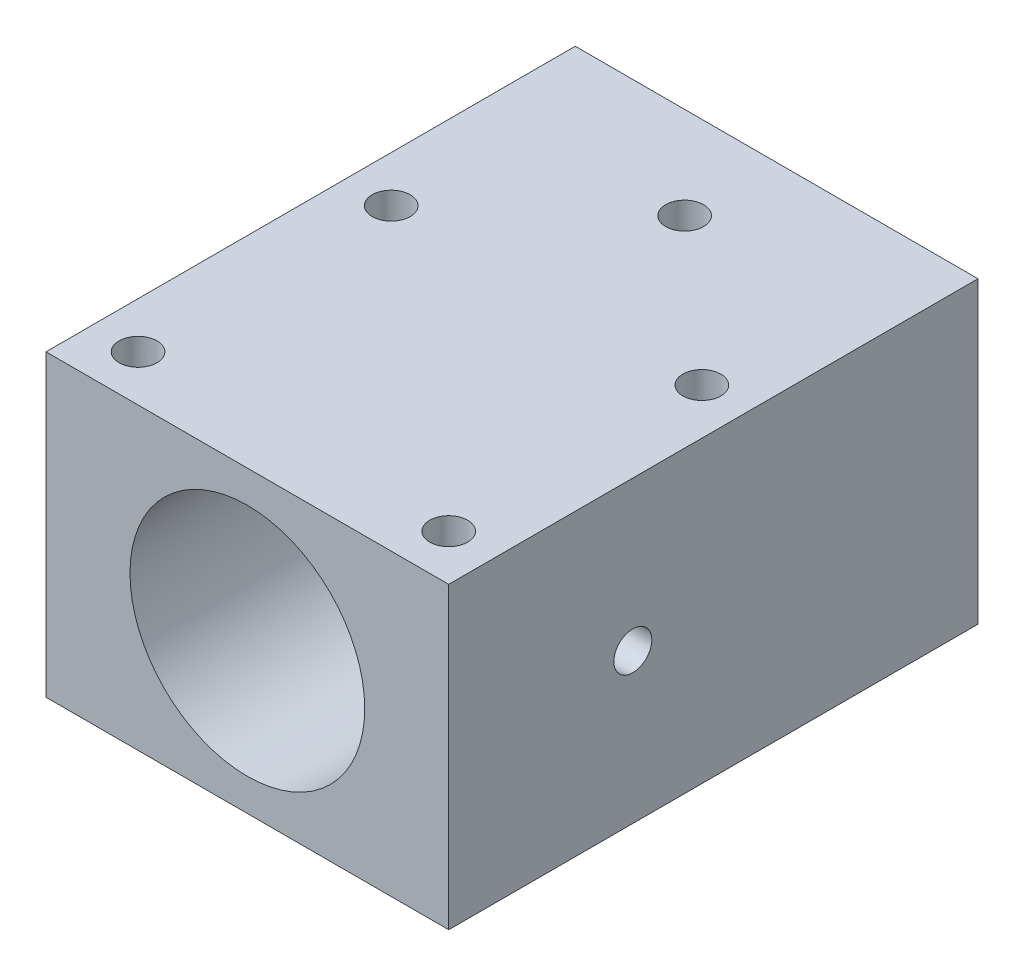
from build123d import *

# Parameters (mm, degrees)
SKETCH1_W           = 35
SKETCH1_H           = 46
BOSS_EXTRUDE1_DEPTH = 13
SKETCH2_R           = 1.65
CUT_EXTRUDE1_DEPTH  = 26
SKETCH5_R           = 10.2
CUT_EXTRUDE2_DEPTH  = 46
SKETCH8_R           = 1.65
CUT_EXTRUDE3_DEPTH  = 26
SKETCH9_R           = 1.65
CUT_EXTRUDE4_DEPTH  = 35


with BuildPart() as part:
    # Sketch1 → Boss-Extrude1 (new body, symmetric)
    with BuildSketch(Plane(origin=(0, 0, 0), x_dir=(1, 0, 0), z_dir=(0, 1, 0))):
        Rectangle(SKETCH1_W, SKETCH1_H)
    extrude(amount=BOSS_EXTRUDE1_DEPTH, both=True)

    # Sketch2 → Cut-Extrude1 (cut)
    with BuildSketch(Plane(origin=(0, 13, 0), x_dir=(1, 0, 0), z_dir=(0, 1, 0))):
        with Locations((-13.5, 3)):
            Circle(SKETCH2_R)
        with Locations((-13.5, -19)):
            Circle(SKETCH2_R)
        with Locations((13.5, -19)):
            Circle(SKETCH2_R)
        with Locations((13.5, 3)):
            Circle(SKETCH2_R)
    extrude(amount=-CUT_EXTRUDE1_DEPTH, mode=Mode.SUBTRACT)

    # Sketch5 → Cut-Extrude2 (cut)
    with BuildSketch(Plane.XY.offset(23)):
        Circle(SKETCH5_R)
    extrude(amount=-CUT_EXTRUDE2_DEPTH, mode=Mode.SUBTRACT)

    # Sketch8 → Cut-Extrude3 (cut)
    with BuildSketch(Plane(origin=(0, 13, 0), x_dir=(1, 0, 0), z_dir=(0, 1, 0))):
        with Locations((0, 15)):
            Circle(SKETCH8_R)
    extrude(amount=-CUT_EXTRUDE3_DEPTH, mode=Mode.SUBTRACT)

    # Sketch9 → Cut-Extrude4 (cut)
    with BuildSketch(Plane.ZY.offset(17.5)):
        with Locations((7, 0)):
            Circle(SKETCH9_R)
    extrude(amount=-CUT_EXTRUDE4_DEPTH, mode=Mode.SUBTRACT)


solid = part.part
